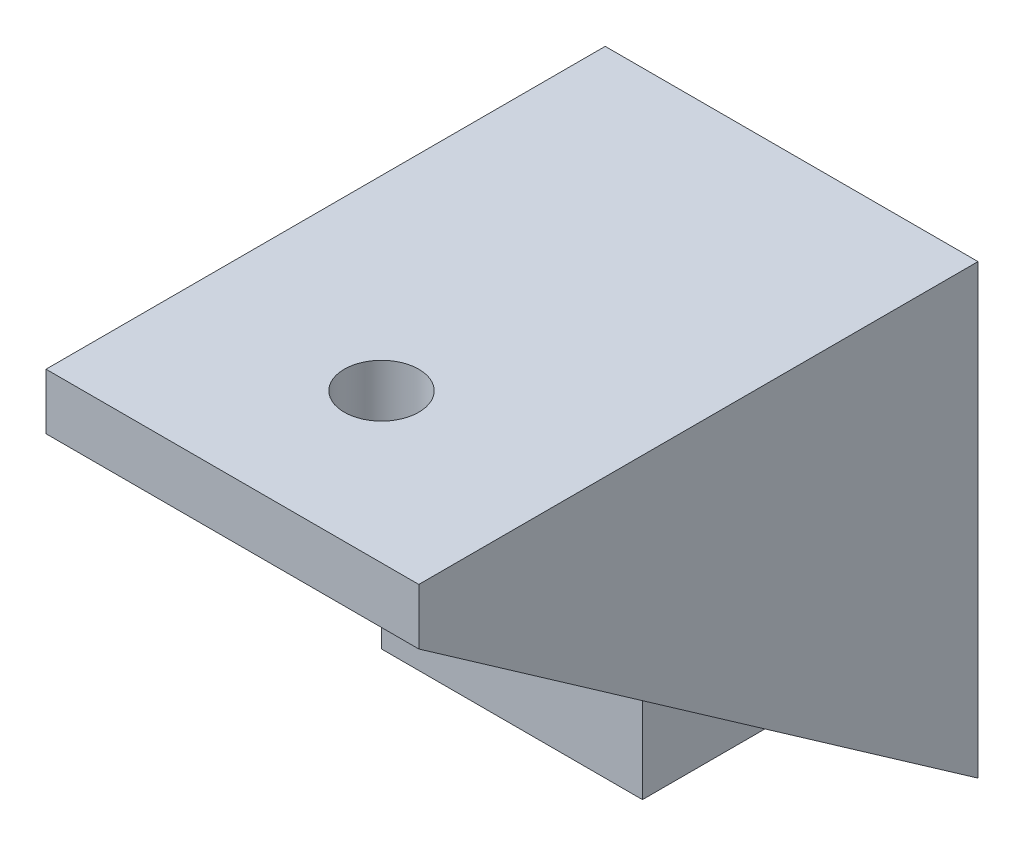
from build123d import *

# Parameters (mm, degrees)
SKETCH1_W           = 20
SKETCH1_H           = 24
BOSS_EXTRUDE1_DEPTH = 30
CUT_EXTRUDE1_DEPTH  = 21
SKETCH3_W           = 16
SKETCH3_H           = 19
CUT_EXTRUDE2_DEPTH  = 27
SKETCH4_W           = 14
SKETCH4_H           = 14
BOSS_EXTRUDE2_DEPTH = 12
SKETCH5_R           = 1.6
CUT_EXTRUDE3_DEPTH  = 31
SKETCH6_R           = 2
CUT_EXTRUDE4_DEPTH  = 4


with BuildPart() as part:
    # Sketch1 → Boss-Extrude1 (new body)
    with BuildSketch(Plane.XY):
        Rectangle(SKETCH1_W, SKETCH1_H)
    extrude(amount=BOSS_EXTRUDE1_DEPTH)

    # Sketch2 → Cut-Extrude1 (cut, through all)
    with BuildSketch(Plane(origin=(10, 0, 0), x_dir=(0, 0, -1), z_dir=(1, 0, 0))):
        Polygon((0, -12), (-30, 9), (-30, -12), align=None)
    extrude(amount=-CUT_EXTRUDE1_DEPTH, mode=Mode.SUBTRACT)

    # Sketch3 → Cut-Extrude2 (cut)
    with BuildSketch(Plane.XY.offset(30)):
        with Locations((0, -0.5)):
            Rectangle(SKETCH3_W, SKETCH3_H)
    extrude(amount=-CUT_EXTRUDE2_DEPTH, mode=Mode.SUBTRACT)

    # Sketch4 → Boss-Extrude2 (add)
    with BuildSketch(Plane.XY.offset(3)):
        Rectangle(SKETCH4_W, SKETCH4_H)
    extrude(amount=BOSS_EXTRUDE2_DEPTH)

    # Sketch5 → Cut-Extrude3 (cut, through all)
    with BuildSketch(Plane(origin=(0, 0, 0), x_dir=(-1, 0, 0), z_dir=(0, 0, -1))):
        Circle(SKETCH5_R)
    extrude(amount=-CUT_EXTRUDE3_DEPTH, mode=Mode.SUBTRACT)

    # Sketch6 → Cut-Extrude4 (cut, through all)
    with BuildSketch(Plane.XZ.offset(-9)):
        with Locations((0, 22)):
            Circle(SKETCH6_R)
    extrude(amount=-CUT_EXTRUDE4_DEPTH, mode=Mode.SUBTRACT)


solid = part.part
